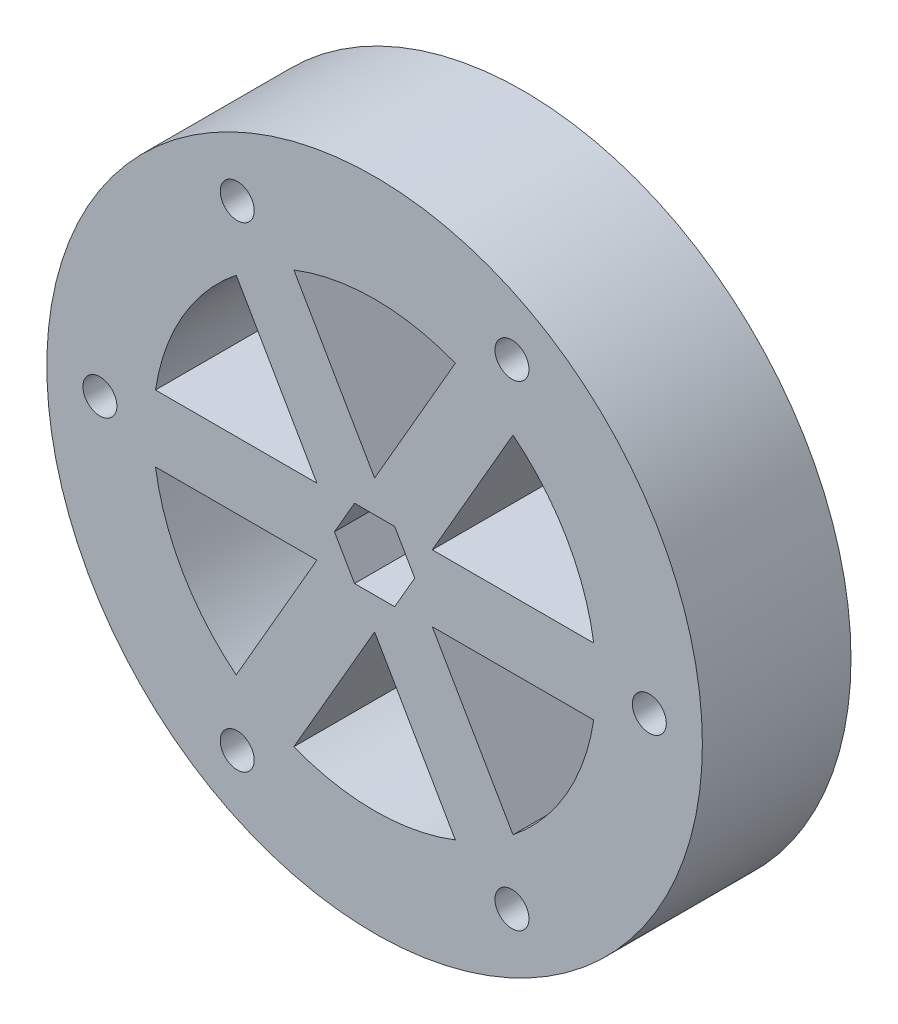
from build123d import *

# Parameters (mm, degrees)
SKETCH2_R             = 30.880396168
HUB_DEPTH             = 14
SKETCH4_R             = 1.6
AXLE_AND_SCREWS_DEPTH = 46.860633827
RIBS_REACH            = 47.861


with BuildPart() as part:
    # Sketch2 → Hub (new body)
    with BuildSketch(Plane.XY):
        Circle(SKETCH2_R)
    extrude(amount=HUB_DEPTH)

    # Sketch4 → Axle and screws (cut, through all)
    with BuildSketch(Plane.XY):
        with Locations((12.940198084, -22.413080541)):
            Circle(SKETCH4_R)
        with Locations((-12.940198084, -22.413080541)):
            Circle(SKETCH4_R)
        with Locations((-25.880396168, 0)):
            Circle(SKETCH4_R)
        with Locations((-12.940198084, 22.413080541)):
            Circle(SKETCH4_R)
        with Locations((12.940198084, 22.413080541)):
            Circle(SKETCH4_R)
        with Locations((25.880396168, 0)):
            Circle(SKETCH4_R)
        Polygon((-1.890822132, -3.275), (1.890822132, -3.275), (3.781644263, 0), (1.890822132, 3.275), (-1.890822132, 3.275), (-3.781644263, 0), align=None)
    extrude(amount=AXLE_AND_SCREWS_DEPTH, mode=Mode.SUBTRACT)

    # Sketch5 → Ribs (cut, up to next)
    with BuildSketch(Plane.XY, mode=Mode.PRIVATE) as ribs_sk1:
        with BuildLine():
            Line((-5.434309409, -3.1375), (-20.643329137, -3.1375))
            ThreePointArc((-20.643329137, -3.1375), (-18.082953522, -10.440198084), (-13.038819273, -16.308897452))
            Line((-13.038819273, -16.308897452), (-5.434309409, -3.1375))
        make_face()
    ribs_tool1 = extrude(ribs_sk1.sketch, amount=RIBS_REACH, mode=Mode.PRIVATE) & part.part
    # Sketch5 → Ribs (cut, up to next)
    with BuildSketch(Plane.XY, mode=Mode.PRIVATE) as ribs_sk2:
        with BuildLine():
            Line((0, -6.275), (-7.604509864, -19.446397452))
            ThreePointArc((-7.604509864, -19.446397452), (0, -20.880396168), (7.604509864, -19.446397452))
            Line((7.604509864, -19.446397452), (0, -6.275))
        make_face()
    ribs_tool2 = extrude(ribs_sk2.sketch, amount=RIBS_REACH, mode=Mode.PRIVATE) & part.part
    # Sketch5 → Ribs (cut, up to next)
    with BuildSketch(Plane.XY, mode=Mode.PRIVATE) as ribs_sk3:
        with BuildLine():
            Line((5.434309409, -3.1375), (13.038819273, -16.308897452))
            ThreePointArc((13.038819273, -16.308897452), (18.082953522, -10.440198084), (20.643329137, -3.1375))
            Line((20.643329137, -3.1375), (5.434309409, -3.1375))
        make_face()
    ribs_tool3 = extrude(ribs_sk3.sketch, amount=RIBS_REACH, mode=Mode.PRIVATE) & part.part
    # Sketch5 → Ribs (cut, up to next)
    with BuildSketch(Plane.XY, mode=Mode.PRIVATE) as ribs_sk4:
        with BuildLine():
            Line((5.434309409, 3.1375), (20.643329137, 3.1375))
            ThreePointArc((20.643329137, 3.1375), (18.082953522, 10.440198084), (13.038819273, 16.308897452))
            Line((13.038819273, 16.308897452), (5.434309409, 3.1375))
        make_face()
    ribs_tool4 = extrude(ribs_sk4.sketch, amount=RIBS_REACH, mode=Mode.PRIVATE) & part.part
    # Sketch5 → Ribs (cut, up to next)
    with BuildSketch(Plane.XY, mode=Mode.PRIVATE) as ribs_sk5:
        with BuildLine():
            Line((-20.643329137, 3.1375), (-5.434309409, 3.1375))
            Line((-5.434309409, 3.1375), (-13.038819273, 16.308897452))
            ThreePointArc((-13.038819273, 16.308897452), (-18.082953522, 10.440198084), (-20.643329137, 3.1375))
        make_face()
    ribs_tool5 = extrude(ribs_sk5.sketch, amount=RIBS_REACH, mode=Mode.PRIVATE) & part.part
    # Sketch5 → Ribs (cut, up to next)
    with BuildSketch(Plane.XY, mode=Mode.PRIVATE) as ribs_sk6:
        with BuildLine():
            Line((0, 6.275), (7.604509864, 19.446397452))
            ThreePointArc((7.604509864, 19.446397452), (0, 20.880396168), (-7.604509864, 19.446397452))
            Line((-7.604509864, 19.446397452), (0, 6.275))
        make_face()
    ribs_tool6 = extrude(ribs_sk6.sketch, amount=RIBS_REACH, mode=Mode.PRIVATE) & part.part
    add(ribs_tool1.solids().sort_by_distance((-13.587324, -7.844645, 0))[0], mode=Mode.SUBTRACT)
    add(ribs_tool2.solids().sort_by_distance((0, -15.68929, 0))[0], mode=Mode.SUBTRACT)
    add(ribs_tool3.solids().sort_by_distance((13.587324, -7.844645, 0))[0], mode=Mode.SUBTRACT)
    add(ribs_tool4.solids().sort_by_distance((13.587324, 7.844645, 0))[0], mode=Mode.SUBTRACT)
    add(ribs_tool5.solids().sort_by_distance((-13.587324, 7.844645, 0))[0], mode=Mode.SUBTRACT)
    add(ribs_tool6.solids().sort_by_distance((0, 15.68929, 0))[0], mode=Mode.SUBTRACT)


solid = part.part
